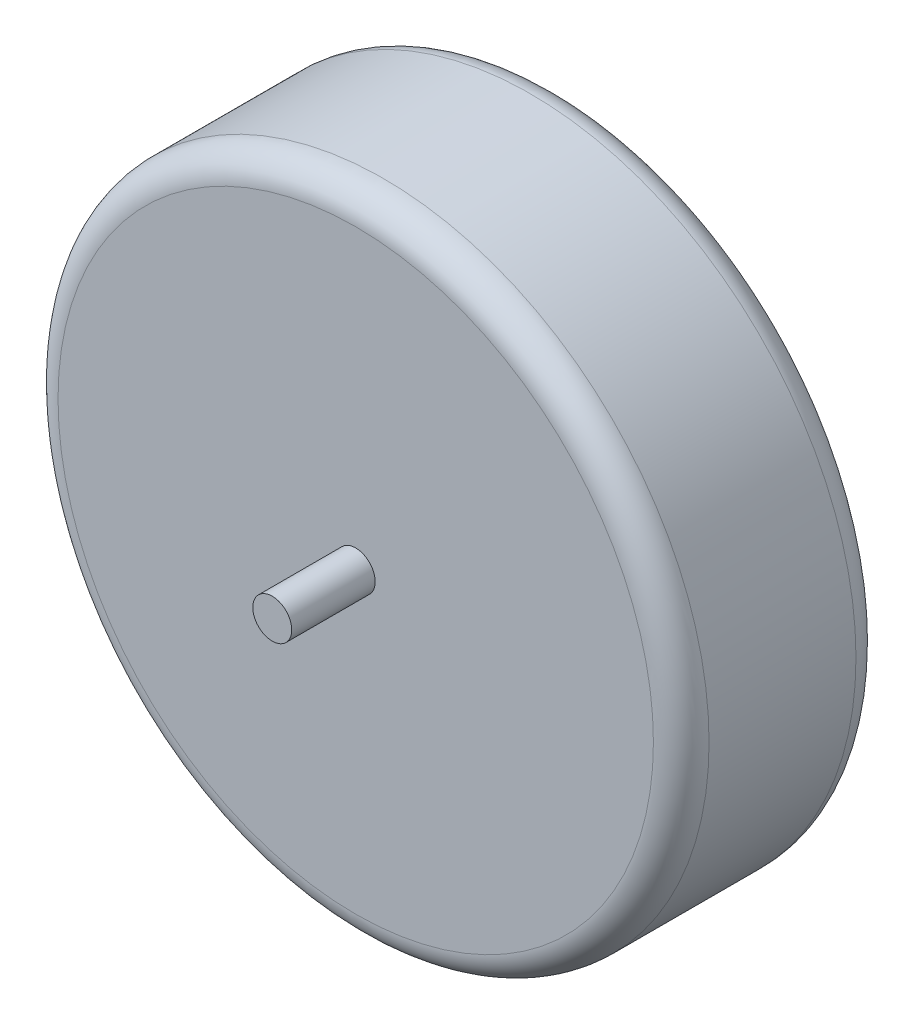
from build123d import *

# Parameters (mm, degrees)
SKETCH1_R                = 74.295
BOSS_EXTRUDE1_DEPTH      = 46.228
FILLET1_R                = 6.35
SKETCH2_R                = 4.445
BOSS_EXTRUDE2_DEPTH      = 19.05
BOSS_EXTRUDE2_DEPTH_BACK = 65.278


with BuildPart() as part:
    # Sketch1 → Boss-Extrude1 (new body)
    with BuildSketch(Plane.XY):
        Circle(SKETCH1_R)
    extrude(amount=BOSS_EXTRUDE1_DEPTH)

    # Fillet1
    fillet1_edges = [part.edges().sort_by_distance(p)[0] for p in [
        (-74.295, 0, 0),
        (-74.295, 0, 46.228),
    ]]
    fillet(fillet1_edges, radius=FILLET1_R)

    # Sketch2 → Boss-Extrude2 (add, two sides)
    with BuildSketch(Plane.XY.offset(46.228)) as boss_extrude2_sk:
        Circle(SKETCH2_R)
    extrude(amount=BOSS_EXTRUDE2_DEPTH)
    extrude(boss_extrude2_sk.sketch, amount=-BOSS_EXTRUDE2_DEPTH_BACK)


solid = part.part
